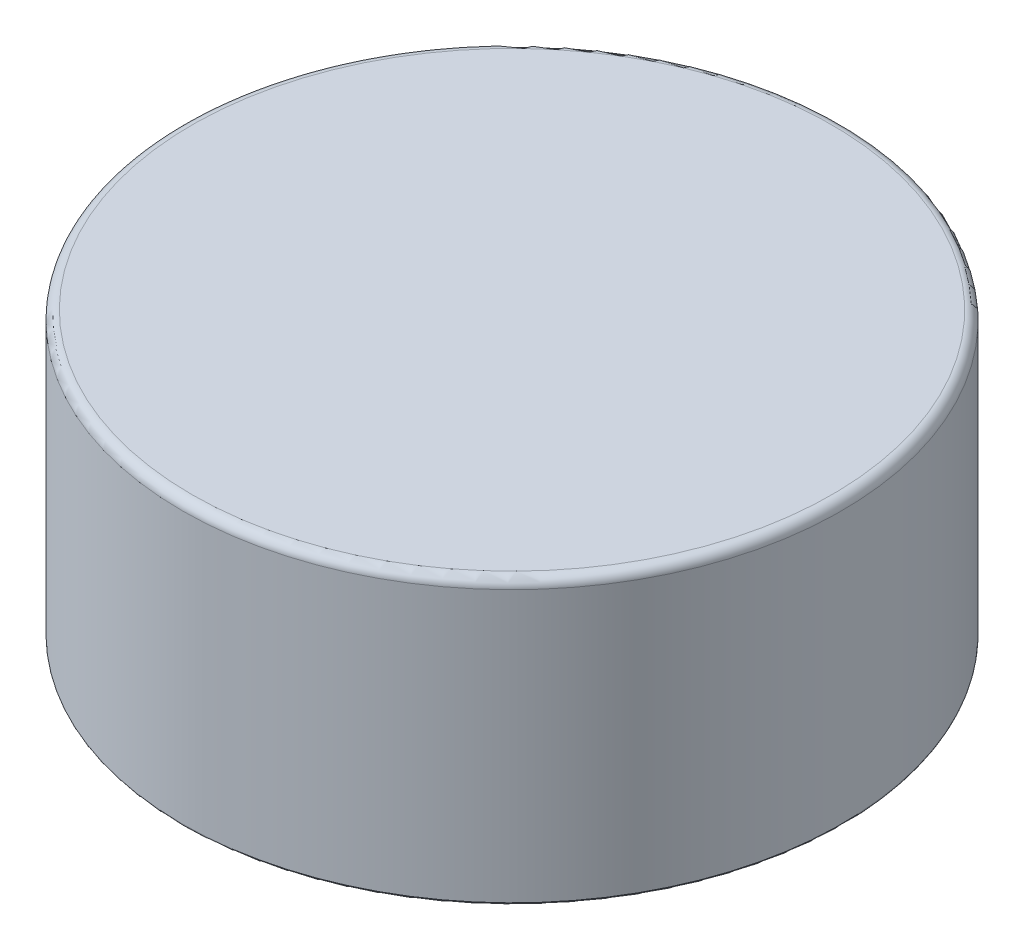
from build123d import *

# Parameters (mm, degrees)
SKETCH1_R           = 35
BOSS_EXTRUDE1_DEPTH = 30
SKETCH2_R           = 34.3
CUT_EXTRUDE1_DEPTH  = 25
FILLET1_R           = 1
FILLET2_R           = 0.2


with BuildPart() as part:
    # Sketch1 → Boss-Extrude1 (new body)
    with BuildSketch(Plane(origin=(0, 0, 0), x_dir=(1, 0, 0), z_dir=(0, 1, 0))):
        Circle(SKETCH1_R)
    extrude(amount=BOSS_EXTRUDE1_DEPTH)

    # Sketch2 → Cut-Extrude1 (cut)
    with BuildSketch(Plane(origin=(0, 0, 0), x_dir=(1, 0, 0), z_dir=(0, 1, 0))):
        Circle(SKETCH2_R)
    extrude(amount=CUT_EXTRUDE1_DEPTH, mode=Mode.SUBTRACT)

    # Fillet1
    fillet1_edges = [part.edges().sort_by_distance(p)[0] for p in [
        (-35, 30, 0),
    ]]
    fillet(fillet1_edges, radius=FILLET1_R)

    # Fillet2
    fillet2_edges = [part.edges().sort_by_distance(p)[0] for p in [
        (-35, 0, 0),
    ]]
    fillet(fillet2_edges, radius=FILLET2_R)


solid = part.part
